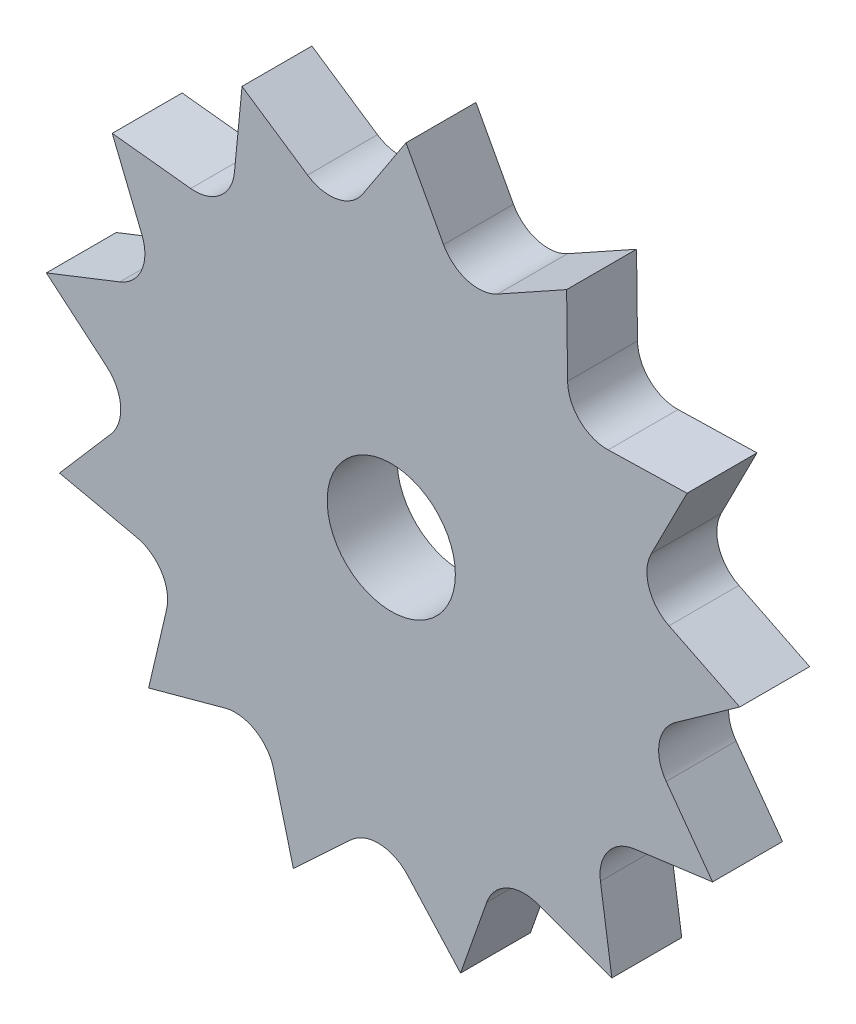
from build123d import *

# Parameters (mm, degrees)
SKETCH1_R           = 15
BOSS_EXTRUDE1_DEPTH = 3
SKETCH2_R           = 2.75
CUT_EXTRUDE1_DEPTH  = 11
SKETCH3_R           = 1.7
CUT_EXTRUDE5_DEPTH  = 10
CIRPATTERN1_COUNT   = 13
CUT_EXTRUDE6_DEPTH  = 10
CIRPATTERN2_COUNT   = 13


with BuildPart() as part:
    # Sketch1 → Boss-Extrude1 (new body)
    with BuildSketch(Plane.XY):
        Circle(SKETCH1_R)
    extrude(amount=BOSS_EXTRUDE1_DEPTH)

    # Sketch2 → Cut-Extrude1 (cut)
    with BuildSketch(Plane.XY.offset(3)):
        Circle(SKETCH2_R)
    extrude(amount=-CUT_EXTRUDE1_DEPTH, mode=Mode.SUBTRACT)

    # Sketch3 → Cut-Extrude5 (cut)
    with BuildSketch(Plane.XY.offset(3)):
        with Locations((3.738719386, 12.815790157)):
            Circle(SKETCH3_R)
    cut_extrude5 = extrude(amount=-CUT_EXTRUDE5_DEPTH, mode=Mode.SUBTRACT)

    # CirPattern1: Cut-Extrude5 ×13 about axis
    cirpattern1_axis = Axis((0, 0, 0), (0, 0, 1))
    for i in range(1, CIRPATTERN1_COUNT):
        add(cut_extrude5.rotate(cirpattern1_axis, i * 360 / CIRPATTERN1_COUNT), mode=Mode.SUBTRACT)

    # Sketch4 → Cut-Extrude6 (cut)
    with BuildSketch(Plane.XY.offset(3)):
        Polygon((-1.22331177, 12.153685267), (0.632651304, 14.986652472), (2.243253238, 12.007346591), (4.816692291, 13.980883612), (-0.349444611, 17.339445828), (-3.866613741, 14.072309299), align=None)
    cut_extrude6 = extrude(amount=-CUT_EXTRUDE6_DEPTH, mode=Mode.SUBTRACT)

    # CirPattern2: Cut-Extrude6 ×13 about axis
    cirpattern2_axis = Axis((0, 0, 0), (0, 0, 1))
    for i in range(1, CIRPATTERN2_COUNT):
        add(cut_extrude6.rotate(cirpattern2_axis, i * 360 / CIRPATTERN2_COUNT), mode=Mode.SUBTRACT)


solid = part.part
